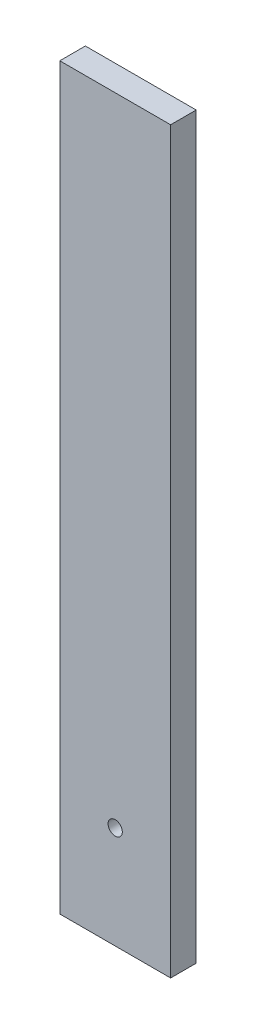
from build123d import *

# Parameters (mm, degrees)
SKETCH1_W          = 195
SKETCH1_H          = 45
SHAPE_DEPTH        = 1300
CUT_EXTRUDE1_REACH = 47
SKETCH2_R          = 12.5


with BuildPart() as part:
    # Sketch1 → Shape (new body)
    with BuildSketch(Plane(origin=(0, 0, 0), x_dir=(1, 0, 0), z_dir=(0, 1, 0))):
        Rectangle(SKETCH1_W, SKETCH1_H)
    extrude(amount=SHAPE_DEPTH)

    # Sketch2 → Cut-Extrude1 (cut, up to next)
    with BuildSketch(Plane.XY.offset(22.5), mode=Mode.PRIVATE) as cut_extrude1_sk1:
        with Locations((0, 180)):
            Circle(SKETCH2_R)
    cut_extrude1_tool1 = extrude(cut_extrude1_sk1.sketch, amount=-CUT_EXTRUDE1_REACH, mode=Mode.PRIVATE) & part.part
    add(cut_extrude1_tool1.solids().sort_by_distance((0, 180, 22.5))[0], mode=Mode.SUBTRACT)


solid = part.part
